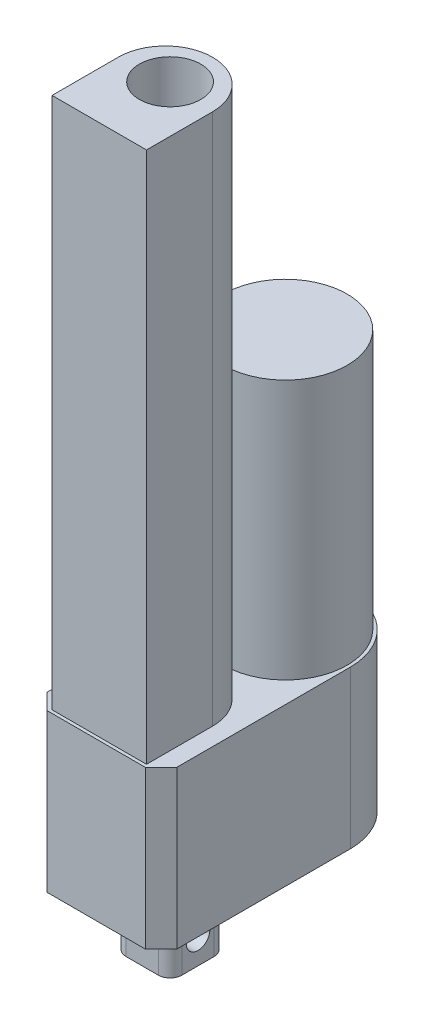
from build123d import *

# Parameters (mm, degrees)
BOSS_EXTRUDE1_DEPTH = 50.8
SKETCH2_R           = 19.939
BOSS_EXTRUDE2_DEPTH = 83.82
BOSS_EXTRUDE3_DEPTH = 171.704
BOSS_EXTRUDE4_DEPTH = 20.066
SKETCH5_R           = 3.81
CUT_EXTRUDE1_DEPTH  = 20.066
SKETCH6_R           = 9.906
CUT_EXTRUDE2_DEPTH  = 127


with BuildPart() as part:
    # Sketch1 → Boss-Extrude1 (new body)
    with BuildSketch(Plane(origin=(0, 0, 0), x_dir=(1, 0, 0), z_dir=(0, 1, 0))):
        with BuildLine():
            Line((-50.83623546, -27.655683544), (-45.75623546, -32.735683544))
            Line((-45.75623546, -32.735683544), (-14.00623546, -32.735683544))
            Line((-14.00623546, -32.735683544), (-8.92623546, -27.655683544))
            Line((-8.92623546, -27.655683544), (-8.92623546, 28.376716456))
            ThreePointArc((-8.92623546, 28.376716456), (-15.056373373, 43.176178544), (-29.85583546, 49.306316456))
            Line((-29.85583546, 49.306316456), (-29.90663546, 49.306316456))
            ThreePointArc((-29.90663546, 49.306316456), (-44.706097548, 43.176178544), (-50.83623546, 28.376716456))
            Line((-50.83623546, 28.376716456), (-50.83623546, -27.655683544))
        make_face()
    extrude(amount=BOSS_EXTRUDE1_DEPTH)

    # Sketch2 → Boss-Extrude2 (add)
    with BuildSketch(Plane(origin=(0, 50.8, 0), x_dir=(1, 0, 0), z_dir=(0, 1, 0))):
        with Locations((-29.88123546, 28.351316456)):
            Circle(SKETCH2_R)
    extrude(amount=BOSS_EXTRUDE2_DEPTH)

    # Sketch3 → Boss-Extrude3 (add)
    with BuildSketch(Plane(origin=(0, 50.8, 0), x_dir=(1, 0, 0), z_dir=(0, 1, 0))):
        with BuildLine():
            Line((-45.12123546, -31.707852889), (-14.64123546, -31.707852889))
            Line((-14.64123546, -31.707852889), (-14.64123546, -10.371852889))
            ThreePointArc((-14.64123546, -10.371852889), (-29.88123546, 4.868147111), (-45.12123546, -10.371852889))
            Line((-45.12123546, -10.371852889), (-45.12123546, -31.707852889))
        make_face()
    extrude(amount=BOSS_EXTRUDE3_DEPTH)

    # Sketch4 → Boss-Extrude4 (add)
    with BuildSketch(Plane(origin=(0, 0, 0), x_dir=(-1, 0, 0), z_dir=(0, -1, 0))):
        with BuildLine():
            Line((24.67423546, 0.157316456), (35.08823546, 0.157316456))
            ThreePointArc((35.08823546, 0.157316456), (37.782312297, -0.958606708), (38.89823546, -3.652683544))
            Line((38.89823546, -3.652683544), (38.89823546, -14.066683544))
            ThreePointArc((38.89823546, -14.066683544), (37.782312297, -16.76076038), (35.08823546, -17.876683544))
            Line((35.08823546, -17.876683544), (24.67423546, -17.876683544))
            ThreePointArc((24.67423546, -17.876683544), (21.980158624, -16.76076038), (20.86423546, -14.066683544))
            Line((20.86423546, -14.066683544), (20.86423546, -3.652683544))
            ThreePointArc((20.86423546, -3.652683544), (21.980158624, -0.958606708), (24.67423546, 0.157316456))
        make_face()
    extrude(amount=BOSS_EXTRUDE4_DEPTH)

    # Sketch5 → Cut-Extrude1 (cut)
    with BuildSketch(Plane.ZY.offset(38.89823546)):
        with Locations((8.859683544, -11.938)):
            Circle(SKETCH5_R)
    extrude(amount=-CUT_EXTRUDE1_DEPTH, mode=Mode.SUBTRACT)

    # Sketch6 → Cut-Extrude2 (cut)
    with BuildSketch(Plane(origin=(0, 222.504, 0), x_dir=(1, 0, 0), z_dir=(0, 1, 0))):
        with Locations((-29.88123546, -8.859683544)):
            Circle(SKETCH6_R)
    extrude(amount=-CUT_EXTRUDE2_DEPTH, mode=Mode.SUBTRACT)


solid = part.part
